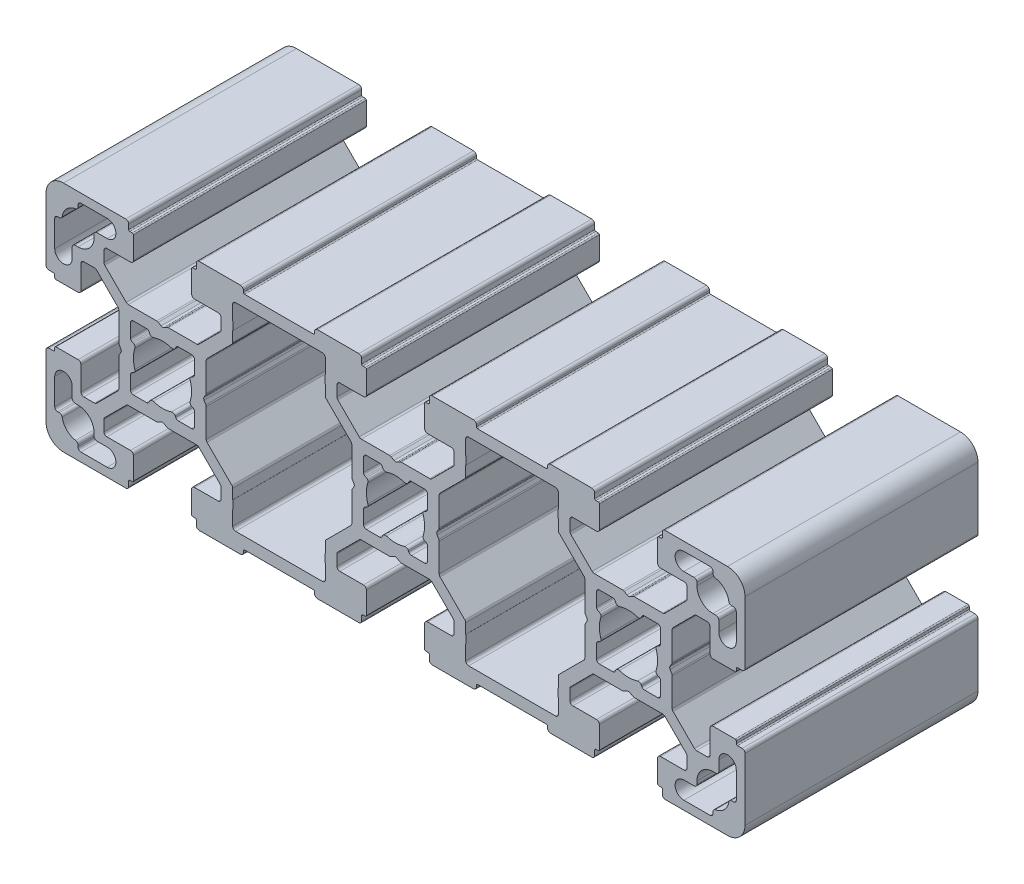
from build123d import *

# Parameters (mm, degrees)
EXTRUDE_1_DEPTH = 40


with BuildPart() as part:
    # Эскиз1 → Бобышка-Вытянуть1 (new body)
    with BuildSketch(Plane.XY):
        with BuildLine():
            Line((-52.669436616, 65.991989417), (-53.169436616, 65.703314282))
            ThreePointArc((-53.169436616, 65.703314282), (-53.419436616, 65.636326984), (-53.669436616, 65.703314282))
            Line((-53.669436616, 65.703314282), (-54.169436616, 65.991989417))
            ThreePointArc((-54.169436616, 65.991989417), (-54.290027094, 66.041939628), (-54.419436616, 66.058976715))
            Line((-54.419436616, 66.058976715), (-59.298116273, 66.058976715))
            ThreePointArc((-59.298116273, 66.058976715), (-59.489457989, 66.097036949), (-59.651669663, 66.205423324))
            Line((-59.651669663, 66.205423324), (-63.322990007, 69.876743668))
            ThreePointArc((-63.322990007, 69.876743668), (-63.431376383, 70.038955342), (-63.469436616, 70.230297059))
            Line((-63.469436616, 70.230297059), (-63.469436616, 72.058976715))
            ThreePointArc((-63.469436616, 72.058976715), (-63.322990007, 72.412530106), (-62.969436616, 72.558976715))
            Line((-62.969436616, 72.558976715), (-58.919436616, 72.558976715))
            ThreePointArc((-58.919436616, 72.558976715), (-58.565883226, 72.705423324), (-58.419436616, 73.058976715))
            Line((-58.419436616, 73.058976715), (-58.419436616, 76.858976715))
            ThreePointArc((-58.419436616, 76.858976715), (-58.47801526, 77.000398071), (-58.619436616, 77.058976715))
            Line((-58.619436616, 77.058976715), (-59.019436616, 77.058976715))
            ThreePointArc((-59.019436616, 77.058976715), (-59.160857973, 77.117555359), (-59.219436616, 77.258976715))
            Line((-59.219436616, 77.258976715), (-59.219436616, 78.058976715))
            ThreePointArc((-59.219436616, 78.058976715), (-59.365883226, 78.412530106), (-59.719436616, 78.558976715))
            Line((-59.719436616, 78.558976715), (-70.419436616, 78.558976715))
            ThreePointArc((-70.419436616, 78.558976715), (-72.54075696, 77.680297059), (-73.419436616, 75.558976715))
            Line((-73.419436616, 75.558976715), (-73.419436616, 64.858976715))
            ThreePointArc((-73.419436616, 64.858976715), (-73.272990007, 64.505423324), (-72.919436616, 64.358976715))
            Line((-72.919436616, 64.358976715), (-72.119436616, 64.358976715))
            ThreePointArc((-72.119436616, 64.358976715), (-71.97801526, 64.300398071), (-71.919436616, 64.158976715))
            Line((-71.919436616, 64.158976715), (-71.919436616, 63.758976715))
            ThreePointArc((-71.919436616, 63.758976715), (-71.860857973, 63.617555359), (-71.719436616, 63.558976715))
            Line((-71.719436616, 63.558976715), (-67.919436616, 63.558976715))
            ThreePointArc((-67.919436616, 63.558976715), (-67.565883226, 63.705423324), (-67.419436616, 64.058976715))
            Line((-67.419436616, 64.058976715), (-67.419436616, 68.108976715))
            ThreePointArc((-67.419436616, 68.108976715), (-67.272990007, 68.462530106), (-66.919436616, 68.608976715))
            Line((-66.919436616, 68.608976715), (-65.09075696, 68.608976715))
            ThreePointArc((-65.09075696, 68.608976715), (-64.899415244, 68.570916481), (-64.737203569, 68.462530106))
            Line((-64.737203569, 68.462530106), (-61.065883226, 64.791209762))
            ThreePointArc((-61.065883226, 64.791209762), (-60.95749685, 64.628998088), (-60.919436616, 64.437656371))
            Line((-60.919436616, 64.437656371), (-60.919436616, 59.558976715))
            ThreePointArc((-60.919436616, 59.558976715), (-60.90239953, 59.429567192), (-60.852449318, 59.308976715))
            Line((-60.852449318, 59.308976715), (-60.563774184, 58.808976715))
            ThreePointArc((-60.563774184, 58.808976715), (-60.496786886, 58.558976715), (-60.563774184, 58.308976715))
            Line((-60.563774184, 58.308976715), (-60.852449318, 57.808976715))
            ThreePointArc((-60.852449318, 57.808976715), (-60.90239953, 57.688386237), (-60.919436616, 57.558976715))
            Line((-60.919436616, 57.558976715), (-60.919436616, 52.680297059))
            ThreePointArc((-60.919436616, 52.680297059), (-60.95749685, 52.488955342), (-61.065883226, 52.326743668))
            Line((-61.065883226, 52.326743668), (-64.737203569, 48.655423324))
            ThreePointArc((-64.737203569, 48.655423324), (-64.899415244, 48.547036949), (-65.09075696, 48.508976715))
            Line((-65.09075696, 48.508976715), (-66.919436616, 48.508976715))
            ThreePointArc((-66.919436616, 48.508976715), (-67.272990007, 48.655423324), (-67.419436616, 49.008976715))
            Line((-67.419436616, 49.008976715), (-67.419436616, 53.058976715))
            ThreePointArc((-67.419436616, 53.058976715), (-67.565883226, 53.412530106), (-67.919436616, 53.558976715))
            Line((-67.919436616, 53.558976715), (-71.719436616, 53.558976715))
            ThreePointArc((-71.719436616, 53.558976715), (-71.860857973, 53.500398071), (-71.919436616, 53.358976715))
            Line((-71.919436616, 53.358976715), (-71.919436616, 52.958976715))
            ThreePointArc((-71.919436616, 52.958976715), (-71.97801526, 52.817555359), (-72.119436616, 52.758976715))
            Line((-72.119436616, 52.758976715), (-72.919436616, 52.758976715))
            ThreePointArc((-72.919436616, 52.758976715), (-73.272990007, 52.612530106), (-73.419436616, 52.258976715))
            Line((-73.419436616, 52.258976715), (-73.419436616, 41.558976715))
            ThreePointArc((-73.419436616, 41.558976715), (-72.54075696, 39.437656371), (-70.419436616, 38.558976715))
            Line((-70.419436616, 38.558976715), (-59.719436616, 38.558976715))
            ThreePointArc((-59.719436616, 38.558976715), (-59.365883226, 38.705423324), (-59.219436616, 39.058976715))
            Line((-59.219436616, 39.058976715), (-59.219436616, 39.858976715))
            ThreePointArc((-59.219436616, 39.858976715), (-59.160857973, 40.000398071), (-59.019436616, 40.058976715))
            Line((-59.019436616, 40.058976715), (-58.619436616, 40.058976715))
            ThreePointArc((-58.619436616, 40.058976715), (-58.47801526, 40.117555359), (-58.419436616, 40.258976715))
            Line((-58.419436616, 40.258976715), (-58.419436616, 44.058976715))
            ThreePointArc((-58.419436616, 44.058976715), (-58.565883226, 44.412530106), (-58.919436616, 44.558976715))
            Line((-58.919436616, 44.558976715), (-62.969436616, 44.558976715))
            ThreePointArc((-62.969436616, 44.558976715), (-63.322990007, 44.705423324), (-63.469436616, 45.058976715))
            Line((-63.469436616, 45.058976715), (-63.469436616, 46.887656371))
            ThreePointArc((-63.469436616, 46.887656371), (-63.431376383, 47.078998088), (-63.322990007, 47.241209762))
            Line((-63.322990007, 47.241209762), (-59.651669663, 50.912530106))
            ThreePointArc((-59.651669663, 50.912530106), (-59.489457989, 51.020916481), (-59.298116273, 51.058976715))
            Line((-59.298116273, 51.058976715), (-54.419436616, 51.058976715))
            ThreePointArc((-54.419436616, 51.058976715), (-54.290027094, 51.076013802), (-54.169436616, 51.125964013))
            Line((-54.169436616, 51.125964013), (-53.669436616, 51.414639148))
            ThreePointArc((-53.669436616, 51.414639148), (-53.419436616, 51.481626446), (-53.169436616, 51.414639148))
            Line((-53.169436616, 51.414639148), (-52.669436616, 51.125964013))
            ThreePointArc((-52.669436616, 51.125964013), (-52.548846139, 51.076013802), (-52.419436616, 51.058976715))
            Line((-52.419436616, 51.058976715), (-47.54075696, 51.058976715))
            ThreePointArc((-47.54075696, 51.058976715), (-47.349415244, 51.020916481), (-47.187203569, 50.912530106))
            Line((-47.187203569, 50.912530106), (-43.515883226, 47.241209762))
            ThreePointArc((-43.515883226, 47.241209762), (-43.40749685, 47.078998088), (-43.369436616, 46.887656371))
            Line((-43.369436616, 46.887656371), (-43.369436616, 45.058976715))
            ThreePointArc((-43.369436616, 45.058976715), (-43.515883226, 44.705423324), (-43.869436616, 44.558976715))
            Line((-43.869436616, 44.558976715), (-47.919436616, 44.558976715))
            ThreePointArc((-47.919436616, 44.558976715), (-48.272990007, 44.412530106), (-48.419436616, 44.058976715))
            Line((-48.419436616, 44.058976715), (-48.419436616, 40.258976715))
            ThreePointArc((-48.419436616, 40.258976715), (-48.360857973, 40.117555359), (-48.219436616, 40.058976715))
            Line((-48.219436616, 40.058976715), (-47.819436616, 40.058976715))
            ThreePointArc((-47.819436616, 40.058976715), (-47.67801526, 40.000398071), (-47.619436616, 39.858976715))
            Line((-47.619436616, 39.858976715), (-47.619436616, 39.058976715))
            ThreePointArc((-47.619436616, 39.058976715), (-47.472990007, 38.705423324), (-47.119436616, 38.558976715))
            Line((-47.119436616, 38.558976715), (-40.029436616, 38.558976715))
            ThreePointArc((-40.029436616, 38.558976715), (-39.675883226, 38.705423324), (-39.529436616, 39.058976715))
            Line((-39.529436616, 39.058976715), (-39.529436616, 39.358976715))
            ThreePointArc((-39.529436616, 39.358976715), (-39.470857973, 39.500398071), (-39.329436616, 39.558976715))
            Line((-39.329436616, 39.558976715), (-27.509436616, 39.558976715))
            ThreePointArc((-27.509436616, 39.558976715), (-27.36801526, 39.500398071), (-27.309436616, 39.358976715))
            Line((-27.309436616, 39.358976715), (-27.309436616, 39.058976715))
            ThreePointArc((-27.309436616, 39.058976715), (-27.162990007, 38.705423324), (-26.809436616, 38.558976715))
            Line((-26.809436616, 38.558976715), (-19.719436616, 38.558976715))
            ThreePointArc((-19.719436616, 38.558976715), (-19.365883226, 38.705423324), (-19.219436616, 39.058976715))
            Line((-19.219436616, 39.058976715), (-19.219436616, 39.858976715))
            ThreePointArc((-19.219436616, 39.858976715), (-19.160857973, 40.000398071), (-19.019436616, 40.058976715))
            Line((-19.019436616, 40.058976715), (-18.619436616, 40.058976715))
            ThreePointArc((-18.619436616, 40.058976715), (-18.47801526, 40.117555359), (-18.419436616, 40.258976715))
            Line((-18.419436616, 40.258976715), (-18.419436616, 44.058976715))
            ThreePointArc((-18.419436616, 44.058976715), (-18.565883226, 44.412530106), (-18.919436616, 44.558976715))
            Line((-18.919436616, 44.558976715), (-22.969436616, 44.558976715))
            ThreePointArc((-22.969436616, 44.558976715), (-23.322990007, 44.705423324), (-23.469436616, 45.058976715))
            Line((-23.469436616, 45.058976715), (-23.469436616, 46.887656371))
            ThreePointArc((-23.469436616, 46.887656371), (-23.431376383, 47.078998088), (-23.322990007, 47.241209762))
            Line((-23.322990007, 47.241209762), (-19.651669663, 50.912530106))
            ThreePointArc((-19.651669663, 50.912530106), (-19.489457989, 51.020916481), (-19.298116273, 51.058976715))
            Line((-19.298116273, 51.058976715), (-14.419436616, 51.058976715))
            ThreePointArc((-14.419436616, 51.058976715), (-14.290027094, 51.076013802), (-14.169436616, 51.125964013))
            Line((-14.169436616, 51.125964013), (-13.669436616, 51.414639148))
            ThreePointArc((-13.669436616, 51.414639148), (-13.419436616, 51.481626446), (-13.169436616, 51.414639148))
            Line((-13.169436616, 51.414639148), (-12.669436616, 51.125964013))
            ThreePointArc((-12.669436616, 51.125964013), (-12.548846139, 51.076013802), (-12.419436616, 51.058976715))
            Line((-12.419436616, 51.058976715), (-7.54075696, 51.058976715))
            ThreePointArc((-7.54075696, 51.058976715), (-7.349415244, 51.020916481), (-7.187203569, 50.912530106))
            Line((-7.187203569, 50.912530106), (-3.515883226, 47.241209762))
            ThreePointArc((-3.515883226, 47.241209762), (-3.40749685, 47.078998088), (-3.369436616, 46.887656371))
            Line((-3.369436616, 46.887656371), (-3.369436616, 45.058976715))
            ThreePointArc((-3.369436616, 45.058976715), (-3.515883226, 44.705423324), (-3.869436616, 44.558976715))
            Line((-3.869436616, 44.558976715), (-7.919436616, 44.558976715))
            ThreePointArc((-7.919436616, 44.558976715), (-8.272990007, 44.412530106), (-8.419436616, 44.058976715))
            Line((-8.419436616, 44.058976715), (-8.419436616, 40.258976715))
            ThreePointArc((-8.419436616, 40.258976715), (-8.360857973, 40.117555359), (-8.219436616, 40.058976715))
            Line((-8.219436616, 40.058976715), (-7.819436616, 40.058976715))
            ThreePointArc((-7.819436616, 40.058976715), (-7.67801526, 40.000398071), (-7.619436616, 39.858976715))
            Line((-7.619436616, 39.858976715), (-7.619436616, 39.058976715))
            ThreePointArc((-7.619436616, 39.058976715), (-7.472990007, 38.705423324), (-7.119436616, 38.558976715))
            Line((-7.119436616, 38.558976715), (-0.029436616, 38.558976715))
            ThreePointArc((-0.029436616, 38.558976715), (0.324116774, 38.705423324), (0.470563384, 39.058976715))
            Line((0.470563384, 39.058976715), (0.470563384, 39.358976715))
            ThreePointArc((0.470563384, 39.358976715), (0.529142027, 39.500398071), (0.670563384, 39.558976715))
            Line((0.670563384, 39.558976715), (12.490563384, 39.558976715))
            ThreePointArc((12.490563384, 39.558976715), (12.63198474, 39.500398071), (12.690563384, 39.358976715))
            Line((12.690563384, 39.358976715), (12.690563384, 39.058976715))
            ThreePointArc((12.690563384, 39.058976715), (12.837009993, 38.705423324), (13.190563384, 38.558976715))
            Line((13.190563384, 38.558976715), (20.280563384, 38.558976715))
            ThreePointArc((20.280563384, 38.558976715), (20.634116774, 38.705423324), (20.780563384, 39.058976715))
            Line((20.780563384, 39.058976715), (20.780563384, 39.858976715))
            ThreePointArc((20.780563384, 39.858976715), (20.839142027, 40.000398071), (20.980563384, 40.058976715))
            Line((20.980563384, 40.058976715), (21.380563384, 40.058976715))
            ThreePointArc((21.380563384, 40.058976715), (21.52198474, 40.117555359), (21.580563384, 40.258976715))
            Line((21.580563384, 40.258976715), (21.580563384, 44.058976715))
            ThreePointArc((21.580563384, 44.058976715), (21.434116774, 44.412530106), (21.080563384, 44.558976715))
            Line((21.080563384, 44.558976715), (17.030563384, 44.558976715))
            ThreePointArc((17.030563384, 44.558976715), (16.677009993, 44.705423324), (16.530563384, 45.058976715))
            Line((16.530563384, 45.058976715), (16.530563384, 46.887656371))
            ThreePointArc((16.530563384, 46.887656371), (16.568623617, 47.078998088), (16.677009993, 47.241209762))
            Line((16.677009993, 47.241209762), (20.348330337, 50.912530106))
            ThreePointArc((20.348330337, 50.912530106), (20.510542011, 51.020916481), (20.701883727, 51.058976715))
            Line((20.701883727, 51.058976715), (25.580563384, 51.058976715))
            ThreePointArc((25.580563384, 51.058976715), (25.709972906, 51.076013802), (25.830563384, 51.125964013))
            Line((25.830563384, 51.125964013), (26.330563384, 51.414639148))
            ThreePointArc((26.330563384, 51.414639148), (26.580563384, 51.481626446), (26.830563384, 51.414639148))
            Line((26.830563384, 51.414639148), (27.330563384, 51.125964013))
            ThreePointArc((27.330563384, 51.125964013), (27.451153861, 51.076013802), (27.580563384, 51.058976715))
            Line((27.580563384, 51.058976715), (32.45924304, 51.058976715))
            ThreePointArc((32.45924304, 51.058976715), (32.650584756, 51.020916481), (32.812796431, 50.912530106))
            Line((32.812796431, 50.912530106), (36.484116774, 47.241209762))
            ThreePointArc((36.484116774, 47.241209762), (36.59250315, 47.078998088), (36.630563384, 46.887656371))
            Line((36.630563384, 46.887656371), (36.630563384, 45.058976715))
            ThreePointArc((36.630563384, 45.058976715), (36.484116774, 44.705423324), (36.130563384, 44.558976715))
            Line((36.130563384, 44.558976715), (32.080563384, 44.558976715))
            ThreePointArc((32.080563384, 44.558976715), (31.727009993, 44.412530106), (31.580563384, 44.058976715))
            Line((31.580563384, 44.058976715), (31.580563384, 40.258976715))
            ThreePointArc((31.580563384, 40.258976715), (31.639142027, 40.117555359), (31.780563384, 40.058976715))
            Line((31.780563384, 40.058976715), (32.180563384, 40.058976715))
            ThreePointArc((32.180563384, 40.058976715), (32.32198474, 40.000398071), (32.380563384, 39.858976715))
            Line((32.380563384, 39.858976715), (32.380563384, 39.058976715))
            ThreePointArc((32.380563384, 39.058976715), (32.527009993, 38.705423324), (32.880563384, 38.558976715))
            Line((32.880563384, 38.558976715), (43.580563384, 38.558976715))
            ThreePointArc((43.580563384, 38.558976715), (45.701883727, 39.437656371), (46.580563384, 41.558976715))
            Line((46.580563384, 41.558976715), (46.580563384, 52.258976715))
            ThreePointArc((46.580563384, 52.258976715), (46.434116774, 52.612530106), (46.080563384, 52.758976715))
            Line((46.080563384, 52.758976715), (45.280563384, 52.758976715))
            ThreePointArc((45.280563384, 52.758976715), (45.139142027, 52.817555359), (45.080563384, 52.958976715))
            Line((45.080563384, 52.958976715), (45.080563384, 53.358976715))
            ThreePointArc((45.080563384, 53.358976715), (45.02198474, 53.500398071), (44.880563384, 53.558976715))
            Line((44.880563384, 53.558976715), (41.080563384, 53.558976715))
            ThreePointArc((41.080563384, 53.558976715), (40.727009993, 53.412530106), (40.580563384, 53.058976715))
            Line((40.580563384, 53.058976715), (40.580563384, 49.008976715))
            ThreePointArc((40.580563384, 49.008976715), (40.434116774, 48.655423324), (40.080563384, 48.508976715))
            Line((40.080563384, 48.508976715), (38.251883727, 48.508976715))
            ThreePointArc((38.251883727, 48.508976715), (38.060542011, 48.547036949), (37.898330337, 48.655423324))
            Line((37.898330337, 48.655423324), (34.227009993, 52.326743668))
            ThreePointArc((34.227009993, 52.326743668), (34.118623617, 52.488955342), (34.080563384, 52.680297059))
            Line((34.080563384, 52.680297059), (34.080563384, 57.558976715))
            ThreePointArc((34.080563384, 57.558976715), (34.063526297, 57.688386237), (34.013576086, 57.808976715))
            Line((34.013576086, 57.808976715), (33.724900951, 58.308976715))
            ThreePointArc((33.724900951, 58.308976715), (33.657913653, 58.558976715), (33.724900951, 58.808976715))
            Line((33.724900951, 58.808976715), (34.013576086, 59.308976715))
            ThreePointArc((34.013576086, 59.308976715), (34.063526297, 59.429567192), (34.080563384, 59.558976715))
            Line((34.080563384, 59.558976715), (34.080563384, 64.437656371))
            ThreePointArc((34.080563384, 64.437656371), (34.118623617, 64.628998088), (34.227009993, 64.791209762))
            Line((34.227009993, 64.791209762), (37.898330337, 68.462530106))
            ThreePointArc((37.898330337, 68.462530106), (38.060542011, 68.570916481), (38.251883727, 68.608976715))
            Line((38.251883727, 68.608976715), (40.080563384, 68.608976715))
            ThreePointArc((40.080563384, 68.608976715), (40.434116774, 68.462530106), (40.580563384, 68.108976715))
            Line((40.580563384, 68.108976715), (40.580563384, 64.058976715))
            ThreePointArc((40.580563384, 64.058976715), (40.727009993, 63.705423324), (41.080563384, 63.558976715))
            Line((41.080563384, 63.558976715), (44.880563384, 63.558976715))
            ThreePointArc((44.880563384, 63.558976715), (45.02198474, 63.617555359), (45.080563384, 63.758976715))
            Line((45.080563384, 63.758976715), (45.080563384, 64.158976715))
            ThreePointArc((45.080563384, 64.158976715), (45.139142027, 64.300398071), (45.280563384, 64.358976715))
            Line((45.280563384, 64.358976715), (46.080563384, 64.358976715))
            ThreePointArc((46.080563384, 64.358976715), (46.434116774, 64.505423324), (46.580563384, 64.858976715))
            Line((46.580563384, 64.858976715), (46.580563384, 75.558976715))
            ThreePointArc((46.580563384, 75.558976715), (45.701883727, 77.680297059), (43.580563384, 78.558976715))
            Line((43.580563384, 78.558976715), (32.880563384, 78.558976715))
            ThreePointArc((32.880563384, 78.558976715), (32.527009993, 78.412530106), (32.380563384, 78.058976715))
            Line((32.380563384, 78.058976715), (32.380563384, 77.258976715))
            ThreePointArc((32.380563384, 77.258976715), (32.32198474, 77.117555359), (32.180563384, 77.058976715))
            Line((32.180563384, 77.058976715), (31.780563384, 77.058976715))
            ThreePointArc((31.780563384, 77.058976715), (31.639142027, 77.000398071), (31.580563384, 76.858976715))
            Line((31.580563384, 76.858976715), (31.580563384, 73.058976715))
            ThreePointArc((31.580563384, 73.058976715), (31.727009993, 72.705423324), (32.080563384, 72.558976715))
            Line((32.080563384, 72.558976715), (36.130563384, 72.558976715))
            ThreePointArc((36.130563384, 72.558976715), (36.484116774, 72.412530106), (36.630563384, 72.058976715))
            Line((36.630563384, 72.058976715), (36.630563384, 70.230297059))
            ThreePointArc((36.630563384, 70.230297059), (36.59250315, 70.038955342), (36.484116774, 69.876743668))
            Line((36.484116774, 69.876743668), (32.812796431, 66.205423324))
            ThreePointArc((32.812796431, 66.205423324), (32.650584756, 66.097036949), (32.45924304, 66.058976715))
            Line((32.45924304, 66.058976715), (27.580563384, 66.058976715))
            ThreePointArc((27.580563384, 66.058976715), (27.451153861, 66.041939628), (27.330563384, 65.991989417))
            Line((27.330563384, 65.991989417), (26.830563384, 65.703314282))
            ThreePointArc((26.830563384, 65.703314282), (26.580563384, 65.636326984), (26.330563384, 65.703314282))
            Line((26.330563384, 65.703314282), (25.830563384, 65.991989417))
            ThreePointArc((25.830563384, 65.991989417), (25.709972906, 66.041939628), (25.580563384, 66.058976715))
            Line((25.580563384, 66.058976715), (20.701883727, 66.058976715))
            ThreePointArc((20.701883727, 66.058976715), (20.510542011, 66.097036949), (20.348330337, 66.205423324))
            Line((20.348330337, 66.205423324), (16.677009993, 69.876743668))
            ThreePointArc((16.677009993, 69.876743668), (16.568623617, 70.038955342), (16.530563384, 70.230297059))
            Line((16.530563384, 70.230297059), (16.530563384, 72.058976715))
            ThreePointArc((16.530563384, 72.058976715), (16.677009993, 72.412530106), (17.030563384, 72.558976715))
            Line((17.030563384, 72.558976715), (21.080563384, 72.558976715))
            ThreePointArc((21.080563384, 72.558976715), (21.434116774, 72.705423324), (21.580563384, 73.058976715))
            Line((21.580563384, 73.058976715), (21.580563384, 76.858976715))
            ThreePointArc((21.580563384, 76.858976715), (21.52198474, 77.000398071), (21.380563384, 77.058976715))
            Line((21.380563384, 77.058976715), (20.980563384, 77.058976715))
            ThreePointArc((20.980563384, 77.058976715), (20.839142027, 77.117555359), (20.780563384, 77.258976715))
            Line((20.780563384, 77.258976715), (20.780563384, 78.058976715))
            ThreePointArc((20.780563384, 78.058976715), (20.634116774, 78.412530106), (20.280563384, 78.558976715))
            Line((20.280563384, 78.558976715), (13.190563384, 78.558976715))
            ThreePointArc((13.190563384, 78.558976715), (12.837009993, 78.412530106), (12.690563384, 78.058976715))
            Line((12.690563384, 78.058976715), (12.690563384, 77.758976715))
            ThreePointArc((12.690563384, 77.758976715), (12.63198474, 77.617555359), (12.490563384, 77.558976715))
            Line((12.490563384, 77.558976715), (0.670563384, 77.558976715))
            ThreePointArc((0.670563384, 77.558976715), (0.529142027, 77.617555359), (0.470563384, 77.758976715))
            Line((0.470563384, 77.758976715), (0.470563384, 78.058976715))
            ThreePointArc((0.470563384, 78.058976715), (0.324116774, 78.412530106), (-0.029436616, 78.558976715))
            Line((-0.029436616, 78.558976715), (-7.119436616, 78.558976715))
            ThreePointArc((-7.119436616, 78.558976715), (-7.472990007, 78.412530106), (-7.619436616, 78.058976715))
            Line((-7.619436616, 78.058976715), (-7.619436616, 77.258976715))
            ThreePointArc((-7.619436616, 77.258976715), (-7.67801526, 77.117555359), (-7.819436616, 77.058976715))
            Line((-7.819436616, 77.058976715), (-8.219436616, 77.058976715))
            ThreePointArc((-8.219436616, 77.058976715), (-8.360857973, 77.000398071), (-8.419436616, 76.858976715))
            Line((-8.419436616, 76.858976715), (-8.419436616, 73.058976715))
            ThreePointArc((-8.419436616, 73.058976715), (-8.272990007, 72.705423324), (-7.919436616, 72.558976715))
            Line((-7.919436616, 72.558976715), (-3.869436616, 72.558976715))
            ThreePointArc((-3.869436616, 72.558976715), (-3.515883226, 72.412530106), (-3.369436616, 72.058976715))
            Line((-3.369436616, 72.058976715), (-3.369436616, 70.230297059))
            ThreePointArc((-3.369436616, 70.230297059), (-3.40749685, 70.038955342), (-3.515883226, 69.876743668))
            Line((-3.515883226, 69.876743668), (-7.187203569, 66.205423324))
            ThreePointArc((-7.187203569, 66.205423324), (-7.349415244, 66.097036949), (-7.54075696, 66.058976715))
            Line((-7.54075696, 66.058976715), (-12.419436616, 66.058976715))
            ThreePointArc((-12.419436616, 66.058976715), (-12.548846139, 66.041939628), (-12.669436616, 65.991989417))
            Line((-12.669436616, 65.991989417), (-13.169436616, 65.703314282))
            ThreePointArc((-13.169436616, 65.703314282), (-13.419436616, 65.636326984), (-13.669436616, 65.703314282))
            Line((-13.669436616, 65.703314282), (-14.169436616, 65.991989417))
            ThreePointArc((-14.169436616, 65.991989417), (-14.290027094, 66.041939628), (-14.419436616, 66.058976715))
            Line((-14.419436616, 66.058976715), (-19.298116273, 66.058976715))
            ThreePointArc((-19.298116273, 66.058976715), (-19.489457989, 66.097036949), (-19.651669663, 66.205423324))
            Line((-19.651669663, 66.205423324), (-23.322990007, 69.876743668))
            ThreePointArc((-23.322990007, 69.876743668), (-23.431376383, 70.038955342), (-23.469436616, 70.230297059))
            Line((-23.469436616, 70.230297059), (-23.469436616, 72.058976715))
            ThreePointArc((-23.469436616, 72.058976715), (-23.322990007, 72.412530106), (-22.969436616, 72.558976715))
            Line((-22.969436616, 72.558976715), (-18.919436616, 72.558976715))
            ThreePointArc((-18.919436616, 72.558976715), (-18.565883226, 72.705423324), (-18.419436616, 73.058976715))
            Line((-18.419436616, 73.058976715), (-18.419436616, 76.858976715))
            ThreePointArc((-18.419436616, 76.858976715), (-18.47801526, 77.000398071), (-18.619436616, 77.058976715))
            Line((-18.619436616, 77.058976715), (-19.019436616, 77.058976715))
            ThreePointArc((-19.019436616, 77.058976715), (-19.160857973, 77.117555359), (-19.219436616, 77.258976715))
            Line((-19.219436616, 77.258976715), (-19.219436616, 78.058976715))
            ThreePointArc((-19.219436616, 78.058976715), (-19.365883226, 78.412530106), (-19.719436616, 78.558976715))
            Line((-19.719436616, 78.558976715), (-26.809436616, 78.558976715))
            ThreePointArc((-26.809436616, 78.558976715), (-27.162990007, 78.412530106), (-27.309436616, 78.058976715))
            Line((-27.309436616, 78.058976715), (-27.309436616, 77.758976715))
            ThreePointArc((-27.309436616, 77.758976715), (-27.36801526, 77.617555359), (-27.509436616, 77.558976715))
            Line((-27.509436616, 77.558976715), (-39.329436616, 77.558976715))
            ThreePointArc((-39.329436616, 77.558976715), (-39.470857973, 77.617555359), (-39.529436616, 77.758976715))
            Line((-39.529436616, 77.758976715), (-39.529436616, 78.058976715))
            ThreePointArc((-39.529436616, 78.058976715), (-39.675883226, 78.412530106), (-40.029436616, 78.558976715))
            Line((-40.029436616, 78.558976715), (-47.119436616, 78.558976715))
            ThreePointArc((-47.119436616, 78.558976715), (-47.472990007, 78.412530106), (-47.619436616, 78.058976715))
            Line((-47.619436616, 78.058976715), (-47.619436616, 77.258976715))
            ThreePointArc((-47.619436616, 77.258976715), (-47.67801526, 77.117555359), (-47.819436616, 77.058976715))
            Line((-47.819436616, 77.058976715), (-48.219436616, 77.058976715))
            ThreePointArc((-48.219436616, 77.058976715), (-48.360857973, 77.000398071), (-48.419436616, 76.858976715))
            Line((-48.419436616, 76.858976715), (-48.419436616, 73.058976715))
            ThreePointArc((-48.419436616, 73.058976715), (-48.272990007, 72.705423324), (-47.919436616, 72.558976715))
            Line((-47.919436616, 72.558976715), (-43.869436616, 72.558976715))
            ThreePointArc((-43.869436616, 72.558976715), (-43.515883226, 72.412530106), (-43.369436616, 72.058976715))
            Line((-43.369436616, 72.058976715), (-43.369436616, 70.230297059))
            ThreePointArc((-43.369436616, 70.230297059), (-43.40749685, 70.038955342), (-43.515883226, 69.876743668))
            Line((-43.515883226, 69.876743668), (-47.187203569, 66.205423324))
            ThreePointArc((-47.187203569, 66.205423324), (-47.349415244, 66.097036949), (-47.54075696, 66.058976715))
            Line((-47.54075696, 66.058976715), (-52.419436616, 66.058976715))
            ThreePointArc((-52.419436616, 66.058976715), (-52.548846139, 66.041939628), (-52.669436616, 65.991989417))
        make_face()
        with BuildLine():
            ThreePointArc((-71.919436616, 49.058976715), (-70.419436616, 50.558976715), (-68.919436616, 49.058976715))
            Line((-68.919436616, 49.058976715), (-68.919436616, 47.308976715))
            ThreePointArc((-68.919436616, 47.308976715), (-68.772990007, 46.955423324), (-68.419436616, 46.808976715))
            Line((-68.419436616, 46.808976715), (-67.919436616, 46.808976715))
            ThreePointArc((-67.919436616, 46.808976715), (-65.974892968, 46.003520363), (-65.169436616, 44.058976715))
            Line((-65.169436616, 44.058976715), (-65.169436616, 43.558976715))
            ThreePointArc((-65.169436616, 43.558976715), (-65.022990007, 43.205423324), (-64.669436616, 43.058976715))
            Line((-64.669436616, 43.058976715), (-62.919436616, 43.058976715))
            ThreePointArc((-62.919436616, 43.058976715), (-61.419436616, 41.558976715), (-62.919436616, 40.058976715))
            Line((-62.919436616, 40.058976715), (-67.419436616, 40.058976715))
            ThreePointArc((-67.419436616, 40.058976715), (-67.772990007, 40.205423324), (-67.919436616, 40.558976715))
            Line((-67.919436616, 40.558976715), (-67.919436616, 40.84766857))
            ThreePointArc((-67.919436616, 40.84766857), (-68.039659354, 41.172890388), (-68.342513539, 41.341715977))
            ThreePointArc((-68.342513539, 41.341715977), (-69.863980265, 42.114433067), (-70.636697354, 43.635899792))
            ThreePointArc((-70.636697354, 43.635899792), (-70.805522943, 43.938753978), (-71.130744761, 44.058976715))
            Line((-71.130744761, 44.058976715), (-71.419436616, 44.058976715))
            ThreePointArc((-71.419436616, 44.058976715), (-71.772990007, 44.205423324), (-71.919436616, 44.558976715))
            Line((-71.919436616, 44.558976715), (-71.919436616, 49.058976715))
        make_face(mode=Mode.SUBTRACT)
        with BuildLine():
            Line((-58.439911428, 60.750473229), (-58.618811151, 60.828261042))
            ThreePointArc((-58.618811151, 60.828261042), (-58.837579694, 61.012644465), (-58.919436616, 61.286791079))
            Line((-58.919436616, 61.286791079), (-58.919436616, 63.558976715))
            ThreePointArc((-58.919436616, 63.558976715), (-58.772990007, 63.912530106), (-58.419436616, 64.058976715))
            Line((-58.419436616, 64.058976715), (-56.147250981, 64.058976715))
            ThreePointArc((-56.147250981, 64.058976715), (-55.873104366, 63.977119793), (-55.688720944, 63.758351249))
            Line((-55.688720944, 63.758351249), (-55.61093313, 63.579451526))
            ThreePointArc((-55.61093313, 63.579451526), (-55.356305675, 63.322291574), (-54.994860686, 63.304294302))
            ThreePointArc((-54.994860686, 63.304294302), (-53.419436616, 63.558976715), (-51.844012547, 63.304294302))
            ThreePointArc((-51.844012547, 63.304294302), (-51.482567558, 63.322291574), (-51.227940103, 63.579451526))
            Line((-51.227940103, 63.579451526), (-51.150152289, 63.758351249))
            ThreePointArc((-51.150152289, 63.758351249), (-50.965768867, 63.977119793), (-50.691622252, 64.058976715))
            Line((-50.691622252, 64.058976715), (-48.419436616, 64.058976715))
            ThreePointArc((-48.419436616, 64.058976715), (-48.065883226, 63.912530106), (-47.919436616, 63.558976715))
            Line((-47.919436616, 63.558976715), (-47.919436616, 61.286791079))
            ThreePointArc((-47.919436616, 61.286791079), (-48.001293538, 61.012644465), (-48.220062082, 60.828261042))
            Line((-48.220062082, 60.828261042), (-48.398961805, 60.750473229))
            ThreePointArc((-48.398961805, 60.750473229), (-48.656121757, 60.495845773), (-48.674119029, 60.134400785))
            ThreePointArc((-48.674119029, 60.134400785), (-48.419436616, 58.558976715), (-48.674119029, 56.983552645))
            ThreePointArc((-48.674119029, 56.983552645), (-48.656121757, 56.622107656), (-48.398961805, 56.367480201))
            Line((-48.398961805, 56.367480201), (-48.220062082, 56.289692388))
            ThreePointArc((-48.220062082, 56.289692388), (-48.001293538, 56.105308965), (-47.919436616, 55.83116235))
            Line((-47.919436616, 55.83116235), (-47.919436616, 53.558976715))
            ThreePointArc((-47.919436616, 53.558976715), (-48.065883226, 53.205423324), (-48.419436616, 53.058976715))
            Line((-48.419436616, 53.058976715), (-50.691622252, 53.058976715))
            ThreePointArc((-50.691622252, 53.058976715), (-50.965768867, 53.140833637), (-51.150152289, 53.35960218))
            Line((-51.150152289, 53.35960218), (-51.227940103, 53.538501904))
            ThreePointArc((-51.227940103, 53.538501904), (-51.482567558, 53.795661856), (-51.844012547, 53.813659128))
            ThreePointArc((-51.844012547, 53.813659128), (-53.419436616, 53.558976715), (-54.994860686, 53.813659128))
            ThreePointArc((-54.994860686, 53.813659128), (-55.356305675, 53.795661856), (-55.61093313, 53.538501904))
            Line((-55.61093313, 53.538501904), (-55.688720944, 53.35960218))
            ThreePointArc((-55.688720944, 53.35960218), (-55.873104366, 53.140833637), (-56.147250981, 53.058976715))
            Line((-56.147250981, 53.058976715), (-58.419436616, 53.058976715))
            ThreePointArc((-58.419436616, 53.058976715), (-58.772990007, 53.205423324), (-58.919436616, 53.558976715))
            Line((-58.919436616, 53.558976715), (-58.919436616, 55.83116235))
            ThreePointArc((-58.919436616, 55.83116235), (-58.837579694, 56.105308965), (-58.618811151, 56.289692388))
            Line((-58.618811151, 56.289692388), (-58.439911428, 56.367480201))
            ThreePointArc((-58.439911428, 56.367480201), (-58.182751476, 56.622107656), (-58.164754203, 56.983552645))
            ThreePointArc((-58.164754203, 56.983552645), (-58.419436616, 58.558976715), (-58.164754203, 60.134400785))
            ThreePointArc((-58.164754203, 60.134400785), (-58.182751476, 60.495845773), (-58.439911428, 60.750473229))
        make_face(mode=Mode.SUBTRACT)
        with BuildLine():
            Line((-8.398961805, 56.367480201), (-8.220062082, 56.289692388))
            ThreePointArc((-8.220062082, 56.289692388), (-8.001293538, 56.105308965), (-7.919436616, 55.83116235))
            Line((-7.919436616, 55.83116235), (-7.919436616, 53.558976715))
            ThreePointArc((-7.919436616, 53.558976715), (-8.065883226, 53.205423324), (-8.419436616, 53.058976715))
            Line((-8.419436616, 53.058976715), (-10.691622252, 53.058976715))
            ThreePointArc((-10.691622252, 53.058976715), (-10.965768867, 53.140833637), (-11.150152289, 53.35960218))
            Line((-11.150152289, 53.35960218), (-11.227940103, 53.538501904))
            ThreePointArc((-11.227940103, 53.538501904), (-11.482567558, 53.795661856), (-11.844012547, 53.813659128))
            ThreePointArc((-11.844012547, 53.813659128), (-13.419436616, 53.558976715), (-14.994860686, 53.813659128))
            ThreePointArc((-14.994860686, 53.813659128), (-15.356305675, 53.795661856), (-15.61093313, 53.538501904))
            Line((-15.61093313, 53.538501904), (-15.688720944, 53.35960218))
            ThreePointArc((-15.688720944, 53.35960218), (-15.873104366, 53.140833637), (-16.147250981, 53.058976715))
            Line((-16.147250981, 53.058976715), (-18.419436616, 53.058976715))
            ThreePointArc((-18.419436616, 53.058976715), (-18.772990007, 53.205423324), (-18.919436616, 53.558976715))
            Line((-18.919436616, 53.558976715), (-18.919436616, 55.83116235))
            ThreePointArc((-18.919436616, 55.83116235), (-18.837579694, 56.105308965), (-18.618811151, 56.289692388))
            Line((-18.618811151, 56.289692388), (-18.439911428, 56.367480201))
            ThreePointArc((-18.439911428, 56.367480201), (-18.182751476, 56.622107656), (-18.164754203, 56.983552645))
            ThreePointArc((-18.164754203, 56.983552645), (-18.419436616, 58.558976715), (-18.164754203, 60.134400785))
            ThreePointArc((-18.164754203, 60.134400785), (-18.182751476, 60.495845773), (-18.439911428, 60.750473229))
            Line((-18.439911428, 60.750473229), (-18.618811151, 60.828261042))
            ThreePointArc((-18.618811151, 60.828261042), (-18.837579694, 61.012644465), (-18.919436616, 61.286791079))
            Line((-18.919436616, 61.286791079), (-18.919436616, 63.558976715))
            ThreePointArc((-18.919436616, 63.558976715), (-18.772990007, 63.912530106), (-18.419436616, 64.058976715))
            Line((-18.419436616, 64.058976715), (-16.147250981, 64.058976715))
            ThreePointArc((-16.147250981, 64.058976715), (-15.873104366, 63.977119793), (-15.688720944, 63.758351249))
            Line((-15.688720944, 63.758351249), (-15.61093313, 63.579451526))
            ThreePointArc((-15.61093313, 63.579451526), (-15.356305675, 63.322291574), (-14.994860686, 63.304294302))
            ThreePointArc((-14.994860686, 63.304294302), (-13.419436616, 63.558976715), (-11.844012547, 63.304294302))
            ThreePointArc((-11.844012547, 63.304294302), (-11.482567558, 63.322291574), (-11.227940103, 63.579451526))
            Line((-11.227940103, 63.579451526), (-11.150152289, 63.758351249))
            ThreePointArc((-11.150152289, 63.758351249), (-10.965768867, 63.977119793), (-10.691622252, 64.058976715))
            Line((-10.691622252, 64.058976715), (-8.419436616, 64.058976715))
            ThreePointArc((-8.419436616, 64.058976715), (-8.065883226, 63.912530106), (-7.919436616, 63.558976715))
            Line((-7.919436616, 63.558976715), (-7.919436616, 61.286791079))
            ThreePointArc((-7.919436616, 61.286791079), (-8.001293538, 61.012644465), (-8.220062082, 60.828261042))
            Line((-8.220062082, 60.828261042), (-8.398961805, 60.750473229))
            ThreePointArc((-8.398961805, 60.750473229), (-8.656121757, 60.495845773), (-8.674119029, 60.134400785))
            ThreePointArc((-8.674119029, 60.134400785), (-8.419436616, 58.558976715), (-8.674119029, 56.983552645))
            ThreePointArc((-8.674119029, 56.983552645), (-8.656121757, 56.622107656), (-8.398961805, 56.367480201))
        make_face(mode=Mode.SUBTRACT)
        with BuildLine():
            Line((41.080563384, 40.84766857), (41.080563384, 40.558976715))
            ThreePointArc((41.080563384, 40.558976715), (40.934116774, 40.205423324), (40.580563384, 40.058976715))
            Line((40.580563384, 40.058976715), (36.080563384, 40.058976715))
            ThreePointArc((36.080563384, 40.058976715), (34.580563384, 41.558976715), (36.080563384, 43.058976715))
            Line((36.080563384, 43.058976715), (37.830563384, 43.058976715))
            ThreePointArc((37.830563384, 43.058976715), (38.184116774, 43.205423324), (38.330563384, 43.558976715))
            Line((38.330563384, 43.558976715), (38.330563384, 44.058976715))
            ThreePointArc((38.330563384, 44.058976715), (39.136019735, 46.003520363), (41.080563384, 46.808976715))
            Line((41.080563384, 46.808976715), (41.580563384, 46.808976715))
            ThreePointArc((41.580563384, 46.808976715), (41.934116774, 46.955423324), (42.080563384, 47.308976715))
            Line((42.080563384, 47.308976715), (42.080563384, 49.058976715))
            ThreePointArc((42.080563384, 49.058976715), (43.580563384, 50.558976715), (45.080563384, 49.058976715))
            Line((45.080563384, 49.058976715), (45.080563384, 44.558976715))
            ThreePointArc((45.080563384, 44.558976715), (44.934116774, 44.205423324), (44.580563384, 44.058976715))
            Line((44.580563384, 44.058976715), (44.291871528, 44.058976715))
            ThreePointArc((44.291871528, 44.058976715), (43.96664971, 43.938753978), (43.797824121, 43.635899792))
            ThreePointArc((43.797824121, 43.635899792), (43.025107032, 42.114433067), (41.503640307, 41.341715977))
            ThreePointArc((41.503640307, 41.341715977), (41.200786121, 41.172890388), (41.080563384, 40.84766857))
        make_face(mode=Mode.SUBTRACT)
        with BuildLine():
            Line((31.601038195, 56.367480201), (31.779937918, 56.289692388))
            ThreePointArc((31.779937918, 56.289692388), (31.998706462, 56.105308965), (32.080563384, 55.83116235))
            Line((32.080563384, 55.83116235), (32.080563384, 53.558976715))
            ThreePointArc((32.080563384, 53.558976715), (31.934116774, 53.205423324), (31.580563384, 53.058976715))
            Line((31.580563384, 53.058976715), (29.308377748, 53.058976715))
            ThreePointArc((29.308377748, 53.058976715), (29.034231133, 53.140833637), (28.849847711, 53.35960218))
            Line((28.849847711, 53.35960218), (28.772059897, 53.538501904))
            ThreePointArc((28.772059897, 53.538501904), (28.517432442, 53.795661856), (28.155987453, 53.813659128))
            ThreePointArc((28.155987453, 53.813659128), (26.580563384, 53.558976715), (25.005139314, 53.813659128))
            ThreePointArc((25.005139314, 53.813659128), (24.643694325, 53.795661856), (24.38906687, 53.538501904))
            Line((24.38906687, 53.538501904), (24.311279056, 53.35960218))
            ThreePointArc((24.311279056, 53.35960218), (24.126895634, 53.140833637), (23.852749019, 53.058976715))
            Line((23.852749019, 53.058976715), (21.580563384, 53.058976715))
            ThreePointArc((21.580563384, 53.058976715), (21.227009993, 53.205423324), (21.080563384, 53.558976715))
            Line((21.080563384, 53.558976715), (21.080563384, 55.83116235))
            ThreePointArc((21.080563384, 55.83116235), (21.162420306, 56.105308965), (21.381188849, 56.289692388))
            Line((21.381188849, 56.289692388), (21.560088572, 56.367480201))
            ThreePointArc((21.560088572, 56.367480201), (21.817248524, 56.622107656), (21.835245797, 56.983552645))
            ThreePointArc((21.835245797, 56.983552645), (21.580563384, 58.558976715), (21.835245797, 60.134400785))
            ThreePointArc((21.835245797, 60.134400785), (21.817248524, 60.495845773), (21.560088572, 60.750473229))
            Line((21.560088572, 60.750473229), (21.381188849, 60.828261042))
            ThreePointArc((21.381188849, 60.828261042), (21.162420306, 61.012644465), (21.080563384, 61.286791079))
            Line((21.080563384, 61.286791079), (21.080563384, 63.558976715))
            ThreePointArc((21.080563384, 63.558976715), (21.227009993, 63.912530106), (21.580563384, 64.058976715))
            Line((21.580563384, 64.058976715), (23.852749019, 64.058976715))
            ThreePointArc((23.852749019, 64.058976715), (24.126895634, 63.977119793), (24.311279056, 63.758351249))
            Line((24.311279056, 63.758351249), (24.38906687, 63.579451526))
            ThreePointArc((24.38906687, 63.579451526), (24.643694325, 63.322291574), (25.005139314, 63.304294302))
            ThreePointArc((25.005139314, 63.304294302), (26.580563384, 63.558976715), (28.155987453, 63.304294302))
            ThreePointArc((28.155987453, 63.304294302), (28.517432442, 63.322291574), (28.772059897, 63.579451526))
            Line((28.772059897, 63.579451526), (28.849847711, 63.758351249))
            ThreePointArc((28.849847711, 63.758351249), (29.034231133, 63.977119793), (29.308377748, 64.058976715))
            Line((29.308377748, 64.058976715), (31.580563384, 64.058976715))
            ThreePointArc((31.580563384, 64.058976715), (31.934116774, 63.912530106), (32.080563384, 63.558976715))
            Line((32.080563384, 63.558976715), (32.080563384, 61.286791079))
            ThreePointArc((32.080563384, 61.286791079), (31.998706462, 61.012644465), (31.779937918, 60.828261042))
            Line((31.779937918, 60.828261042), (31.601038195, 60.750473229))
            ThreePointArc((31.601038195, 60.750473229), (31.343878243, 60.495845773), (31.325880971, 60.134400785))
            ThreePointArc((31.325880971, 60.134400785), (31.580563384, 58.558976715), (31.325880971, 56.983552645))
            ThreePointArc((31.325880971, 56.983552645), (31.343878243, 56.622107656), (31.601038195, 56.367480201))
        make_face(mode=Mode.SUBTRACT)
        with BuildLine():
            Line((-42.101669663, 48.655423324), (-45.772990007, 52.326743668))
            ThreePointArc((-45.772990007, 52.326743668), (-45.881376383, 52.488955342), (-45.919436616, 52.680297059))
            Line((-45.919436616, 52.680297059), (-45.919436616, 57.558976715))
            ThreePointArc((-45.919436616, 57.558976715), (-45.936473703, 57.688386237), (-45.986423914, 57.808976715))
            Line((-45.986423914, 57.808976715), (-46.275099049, 58.308976715))
            ThreePointArc((-46.275099049, 58.308976715), (-46.342086347, 58.558976715), (-46.275099049, 58.808976715))
            Line((-46.275099049, 58.808976715), (-45.986423914, 59.308976715))
            ThreePointArc((-45.986423914, 59.308976715), (-45.936473703, 59.429567192), (-45.919436616, 59.558976715))
            Line((-45.919436616, 59.558976715), (-45.919436616, 64.437656371))
            ThreePointArc((-45.919436616, 64.437656371), (-45.881376383, 64.628998088), (-45.772990007, 64.791209762))
            Line((-45.772990007, 64.791209762), (-42.101669663, 68.462530106))
            Line((-42.101669663, 68.462530106), (-41.515883226, 69.048316543))
            ThreePointArc((-41.515883226, 69.048316543), (-41.40749685, 69.210528218), (-41.369436616, 69.401869934))
            Line((-41.369436616, 69.401869934), (-41.369436616, 71.144636887))
            Line((-41.369436616, 71.144636887), (-41.354446236, 71.139106279))
            Line((-41.354446236, 71.139106279), (-41.367735071, 75.057280931))
            ThreePointArc((-41.367735071, 75.057280931), (-41.22189038, 75.411930046), (-40.867737947, 75.558976715))
            Line((-40.867737947, 75.558976715), (-25.971135286, 75.558976715))
            ThreePointArc((-25.971135286, 75.558976715), (-25.616982853, 75.411930046), (-25.471138162, 75.057280931))
            Line((-25.471138162, 75.057280931), (-25.484426997, 71.139106279))
            Line((-25.484426997, 71.139106279), (-25.469436616, 71.144636887))
            Line((-25.469436616, 71.144636887), (-25.469436616, 69.401869934))
            ThreePointArc((-25.469436616, 69.401869934), (-25.431376383, 69.210528218), (-25.322990007, 69.048316543))
            Line((-25.322990007, 69.048316543), (-24.737203569, 68.462530106))
            Line((-24.737203569, 68.462530106), (-21.065883226, 64.791209762))
            ThreePointArc((-21.065883226, 64.791209762), (-20.95749685, 64.628998088), (-20.919436616, 64.437656371))
            Line((-20.919436616, 64.437656371), (-20.919436616, 59.558976715))
            ThreePointArc((-20.919436616, 59.558976715), (-20.90239953, 59.429567192), (-20.852449318, 59.308976715))
            Line((-20.852449318, 59.308976715), (-20.563774184, 58.808976715))
            ThreePointArc((-20.563774184, 58.808976715), (-20.496786886, 58.558976715), (-20.563774184, 58.308976715))
            Line((-20.563774184, 58.308976715), (-20.852449318, 57.808976715))
            ThreePointArc((-20.852449318, 57.808976715), (-20.90239953, 57.688386237), (-20.919436616, 57.558976715))
            Line((-20.919436616, 57.558976715), (-20.919436616, 52.680297059))
            ThreePointArc((-20.919436616, 52.680297059), (-20.95749685, 52.488955342), (-21.065883226, 52.326743668))
            Line((-21.065883226, 52.326743668), (-24.737203569, 48.655423324))
            Line((-24.737203569, 48.655423324), (-25.322990007, 48.069636887))
            ThreePointArc((-25.322990007, 48.069636887), (-25.431376383, 47.907425212), (-25.469436616, 47.716083496))
            Line((-25.469436616, 47.716083496), (-25.469436616, 45.973316543))
            Line((-25.469436616, 45.973316543), (-25.484426997, 45.978847151))
            Line((-25.484426997, 45.978847151), (-25.471138162, 42.060672499))
            ThreePointArc((-25.471138162, 42.060672499), (-25.616982853, 41.706023384), (-25.971135286, 41.558976715))
            Line((-25.971135286, 41.558976715), (-40.867737947, 41.558976715))
            ThreePointArc((-40.867737947, 41.558976715), (-41.22189038, 41.706023384), (-41.367735071, 42.060672499))
            Line((-41.367735071, 42.060672499), (-41.354446236, 45.978847151))
            Line((-41.354446236, 45.978847151), (-41.369436616, 45.973316543))
            Line((-41.369436616, 45.973316543), (-41.369436616, 47.716083496))
            ThreePointArc((-41.369436616, 47.716083496), (-41.40749685, 47.907425212), (-41.515883226, 48.069636887))
            Line((-41.515883226, 48.069636887), (-42.101669663, 48.655423324))
        make_face(mode=Mode.SUBTRACT)
        with BuildLine():
            Line((-67.919436616, 76.27028486), (-67.919436616, 76.558976715))
            ThreePointArc((-67.919436616, 76.558976715), (-67.772990007, 76.912530106), (-67.419436616, 77.058976715))
            Line((-67.419436616, 77.058976715), (-62.919436616, 77.058976715))
            ThreePointArc((-62.919436616, 77.058976715), (-61.419436616, 75.558976715), (-62.919436616, 74.058976715))
            Line((-62.919436616, 74.058976715), (-64.669436616, 74.058976715))
            ThreePointArc((-64.669436616, 74.058976715), (-65.022990007, 73.912530106), (-65.169436616, 73.558976715))
            Line((-65.169436616, 73.558976715), (-65.169436616, 73.058976715))
            ThreePointArc((-65.169436616, 73.058976715), (-65.974892968, 71.114433067), (-67.919436616, 70.308976715))
            Line((-67.919436616, 70.308976715), (-68.419436616, 70.308976715))
            ThreePointArc((-68.419436616, 70.308976715), (-68.772990007, 70.162530106), (-68.919436616, 69.808976715))
            Line((-68.919436616, 69.808976715), (-68.919436616, 68.058976715))
            ThreePointArc((-68.919436616, 68.058976715), (-70.419436616, 66.558976715), (-71.919436616, 68.058976715))
            Line((-71.919436616, 68.058976715), (-71.919436616, 72.558976715))
            ThreePointArc((-71.919436616, 72.558976715), (-71.772990007, 72.912530106), (-71.419436616, 73.058976715))
            Line((-71.419436616, 73.058976715), (-71.130744761, 73.058976715))
            ThreePointArc((-71.130744761, 73.058976715), (-70.805522943, 73.179199452), (-70.636697354, 73.482053638))
            ThreePointArc((-70.636697354, 73.482053638), (-69.863980265, 75.003520363), (-68.342513539, 75.776237453))
            ThreePointArc((-68.342513539, 75.776237453), (-68.039659354, 75.945063042), (-67.919436616, 76.27028486))
        make_face(mode=Mode.SUBTRACT)
        with BuildLine():
            Line((-2.101669663, 48.655423324), (-5.772990007, 52.326743668))
            ThreePointArc((-5.772990007, 52.326743668), (-5.881376383, 52.488955342), (-5.919436616, 52.680297059))
            Line((-5.919436616, 52.680297059), (-5.919436616, 57.558976715))
            ThreePointArc((-5.919436616, 57.558976715), (-5.936473703, 57.688386237), (-5.986423914, 57.808976715))
            Line((-5.986423914, 57.808976715), (-6.275099049, 58.308976715))
            ThreePointArc((-6.275099049, 58.308976715), (-6.342086347, 58.558976715), (-6.275099049, 58.808976715))
            Line((-6.275099049, 58.808976715), (-5.986423914, 59.308976715))
            ThreePointArc((-5.986423914, 59.308976715), (-5.936473703, 59.429567192), (-5.919436616, 59.558976715))
            Line((-5.919436616, 59.558976715), (-5.919436616, 64.437656371))
            ThreePointArc((-5.919436616, 64.437656371), (-5.881376383, 64.628998088), (-5.772990007, 64.791209762))
            Line((-5.772990007, 64.791209762), (-2.101669663, 68.462530106))
            Line((-2.101669663, 68.462530106), (-1.515883226, 69.048316543))
            ThreePointArc((-1.515883226, 69.048316543), (-1.40749685, 69.210528218), (-1.369436616, 69.401869934))
            Line((-1.369436616, 69.401869934), (-1.369436616, 71.144636887))
            Line((-1.369436616, 71.144636887), (-1.354446236, 71.139106279))
            Line((-1.354446236, 71.139106279), (-1.367735071, 75.057280931))
            ThreePointArc((-1.367735071, 75.057280931), (-1.22189038, 75.411930046), (-0.867737947, 75.558976715))
            Line((-0.867737947, 75.558976715), (14.028864714, 75.558976715))
            ThreePointArc((14.028864714, 75.558976715), (14.383017147, 75.411930046), (14.528861838, 75.057280931))
            Line((14.528861838, 75.057280931), (14.515573003, 71.139106279))
            Line((14.515573003, 71.139106279), (14.530563384, 71.144636887))
            Line((14.530563384, 71.144636887), (14.530563384, 69.401869934))
            ThreePointArc((14.530563384, 69.401869934), (14.568623617, 69.210528218), (14.677009993, 69.048316543))
            Line((14.677009993, 69.048316543), (15.262796431, 68.462530106))
            Line((15.262796431, 68.462530106), (18.934116774, 64.791209762))
            ThreePointArc((18.934116774, 64.791209762), (19.04250315, 64.628998088), (19.080563384, 64.437656371))
            Line((19.080563384, 64.437656371), (19.080563384, 59.558976715))
            ThreePointArc((19.080563384, 59.558976715), (19.09760047, 59.429567192), (19.147550682, 59.308976715))
            Line((19.147550682, 59.308976715), (19.436225816, 58.808976715))
            ThreePointArc((19.436225816, 58.808976715), (19.503213114, 58.558976715), (19.436225816, 58.308976715))
            Line((19.436225816, 58.308976715), (19.147550682, 57.808976715))
            ThreePointArc((19.147550682, 57.808976715), (19.09760047, 57.688386237), (19.080563384, 57.558976715))
            Line((19.080563384, 57.558976715), (19.080563384, 52.680297059))
            ThreePointArc((19.080563384, 52.680297059), (19.04250315, 52.488955342), (18.934116774, 52.326743668))
            Line((18.934116774, 52.326743668), (15.262796431, 48.655423324))
            Line((15.262796431, 48.655423324), (14.677009993, 48.069636887))
            ThreePointArc((14.677009993, 48.069636887), (14.568623617, 47.907425212), (14.530563384, 47.716083496))
            Line((14.530563384, 47.716083496), (14.530563384, 45.973316543))
            Line((14.530563384, 45.973316543), (14.515573003, 45.978847151))
            Line((14.515573003, 45.978847151), (14.528861838, 42.060672499))
            ThreePointArc((14.528861838, 42.060672499), (14.383017147, 41.706023384), (14.028864714, 41.558976715))
            Line((14.028864714, 41.558976715), (-0.867737947, 41.558976715))
            ThreePointArc((-0.867737947, 41.558976715), (-1.22189038, 41.706023384), (-1.367735071, 42.060672499))
            Line((-1.367735071, 42.060672499), (-1.354446236, 45.978847151))
            Line((-1.354446236, 45.978847151), (-1.369436616, 45.973316543))
            Line((-1.369436616, 45.973316543), (-1.369436616, 47.716083496))
            ThreePointArc((-1.369436616, 47.716083496), (-1.40749685, 47.907425212), (-1.515883226, 48.069636887))
            Line((-1.515883226, 48.069636887), (-2.101669663, 48.655423324))
        make_face(mode=Mode.SUBTRACT)
        with BuildLine():
            ThreePointArc((45.080563384, 68.058976715), (43.580563384, 66.558976715), (42.080563384, 68.058976715))
            Line((42.080563384, 68.058976715), (42.080563384, 69.808976715))
            ThreePointArc((42.080563384, 69.808976715), (41.934116774, 70.162530106), (41.580563384, 70.308976715))
            Line((41.580563384, 70.308976715), (41.080563384, 70.308976715))
            ThreePointArc((41.080563384, 70.308976715), (39.136019735, 71.114433067), (38.330563384, 73.058976715))
            Line((38.330563384, 73.058976715), (38.330563384, 73.558976715))
            ThreePointArc((38.330563384, 73.558976715), (38.184116774, 73.912530106), (37.830563384, 74.058976715))
            Line((37.830563384, 74.058976715), (36.080563384, 74.058976715))
            ThreePointArc((36.080563384, 74.058976715), (34.580563384, 75.558976715), (36.080563384, 77.058976715))
            Line((36.080563384, 77.058976715), (40.580563384, 77.058976715))
            ThreePointArc((40.580563384, 77.058976715), (40.934116774, 76.912530106), (41.080563384, 76.558976715))
            Line((41.080563384, 76.558976715), (41.080563384, 76.27028486))
            ThreePointArc((41.080563384, 76.27028486), (41.200786121, 75.945063042), (41.503640307, 75.776237453))
            ThreePointArc((41.503640307, 75.776237453), (43.025107032, 75.003520363), (43.797824121, 73.482053638))
            ThreePointArc((43.797824121, 73.482053638), (43.96664971, 73.179199452), (44.291871528, 73.058976715))
            Line((44.291871528, 73.058976715), (44.580563384, 73.058976715))
            ThreePointArc((44.580563384, 73.058976715), (44.934116774, 72.912530106), (45.080563384, 72.558976715))
            Line((45.080563384, 72.558976715), (45.080563384, 68.058976715))
        make_face(mode=Mode.SUBTRACT)
    extrude(amount=EXTRUDE_1_DEPTH)


solid = part.part
